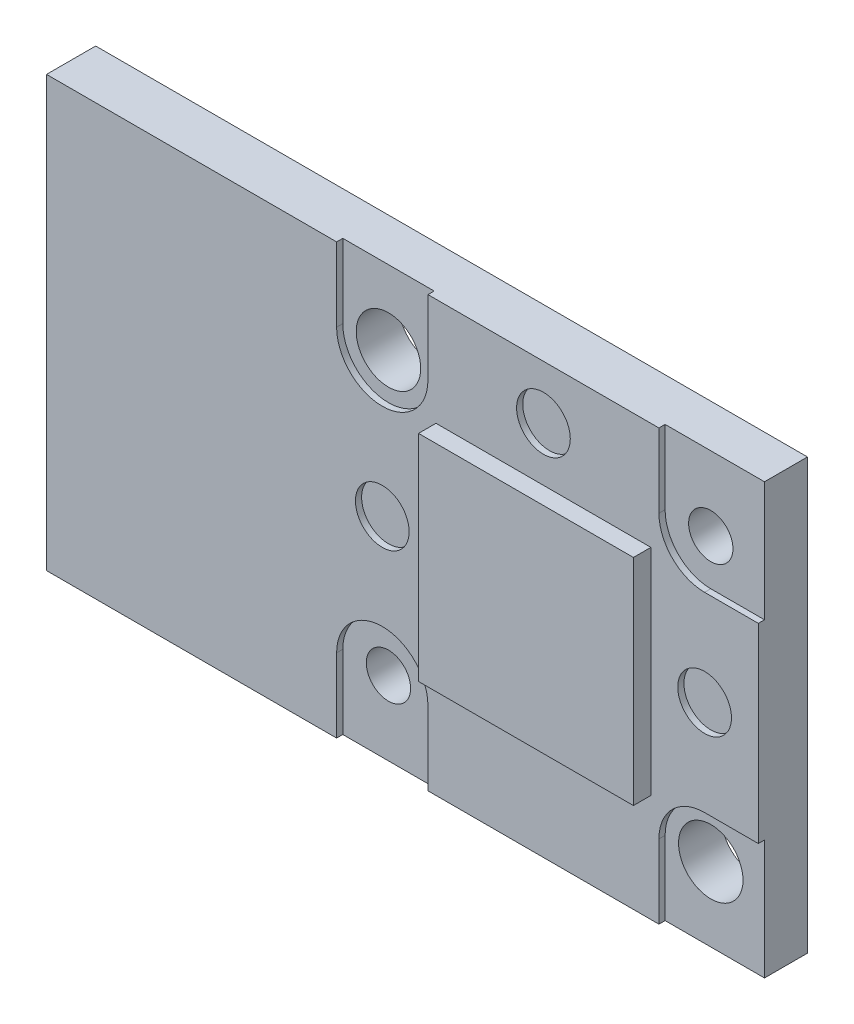
from build123d import *

# Parameters (mm, degrees)
SKETCH1_W           = 26.5
SKETCH1_H           = 16
BOSS_EXTRUDE1_DEPTH = 1.6
SKETCH2_R           = 1.2
SKETCH2_R_2         = 0.825
CUT_EXTRUDE1_DEPTH  = 2.6
SKETCH3_R           = 1
BOSS_EXTRUDE2_DEPTH = 0.23
SKETCH4_W           = 2
SKETCH4_H           = 2.7
BOSS_EXTRUDE3_DEPTH = 0.2
SKETCH5_W           = 8
SKETCH5_H           = 8
BOSS_EXTRUDE4_DEPTH = 0.65


with BuildPart() as part:
    # Sketch1 → Boss-Extrude1 (new body)
    with BuildSketch(Plane.XY):
        Rectangle(SKETCH1_W, SKETCH1_H)
    extrude(amount=BOSS_EXTRUDE1_DEPTH)

    # Sketch2 → Cut-Extrude1 (cut, through all)
    with BuildSketch(Plane.XY.offset(1.6)):
        with Locations((-0.75, 5.25)):
            Circle(SKETCH2_R)
        with Locations((11.25, 5.25)):
            Circle(SKETCH2_R_2)
        with Locations((11.25, -5.25)):
            Circle(SKETCH2_R)
        with Locations((-0.75, -5.25)):
            Circle(SKETCH2_R_2)
    extrude(amount=-CUT_EXTRUDE1_DEPTH, mode=Mode.SUBTRACT)

    # Sketch3 → Boss-Extrude2 (add)
    with BuildSketch(Plane.XY.offset(1.6)):
        with BuildLine():
            Line((11.25, 3.55), (13.25, 3.55))
            Line((13.25, 3.55), (13.25, -3.55))
            Line((13.25, -3.55), (11.25, -3.55))
            ThreePointArc((11.25, -3.55), (10.047918472, -4.047918472), (9.55, -5.25))
            Line((9.55, -5.25), (9.55, -8))
            Line((9.55, -8), (0.95, -8))
            Line((0.95, -8), (0.95, -5.25))
            ThreePointArc((0.95, -5.25), (-0.75, -3.55), (-2.45, -5.25))
            Line((-2.45, -5.25), (-2.45, -8))
            Line((-2.45, -8), (-13.25, -8))
            Line((-13.25, -8), (-13.25, 8))
            Line((-13.25, 8), (-2.45, 8))
            Line((-2.45, 8), (-2.45, 5.25))
            ThreePointArc((-2.45, 5.25), (-0.75, 3.55), (0.95, 5.25))
            Line((0.95, 5.25), (0.95, 8))
            Line((0.95, 8), (9.55, 8))
            Line((9.55, 8), (9.55, 5.25))
            ThreePointArc((9.55, 5.25), (10.047918472, 4.047918472), (11.25, 3.55))
        make_face()
        with Locations((5.25, 6)):
            Circle(SKETCH3_R, mode=Mode.SUBTRACT)
        with Locations((11.25, 0)):
            Circle(SKETCH3_R, mode=Mode.SUBTRACT)
        with Locations((-0.75, 0)):
            Circle(SKETCH3_R, mode=Mode.SUBTRACT)
    extrude(amount=BOSS_EXTRUDE2_DEPTH)


with BuildPart() as body_2:
    # Sketch4 → Boss-Extrude3 (new body)
    with BuildSketch(Plane.XY.offset(1.83)):
        with Locations((5.25, 0)):
            Rectangle(SKETCH4_W, SKETCH4_H)
    extrude(amount=BOSS_EXTRUDE3_DEPTH)


with BuildPart() as body_3:
    # Sketch5 → Boss-Extrude4 (new body)
    with BuildSketch(Plane.XY.offset(1.83)):
        with Locations((5.25, 0)):
            Rectangle(SKETCH5_W, SKETCH5_H)
    extrude(amount=BOSS_EXTRUDE4_DEPTH)


solid = Compound([part.part, body_2.part, body_3.part])
